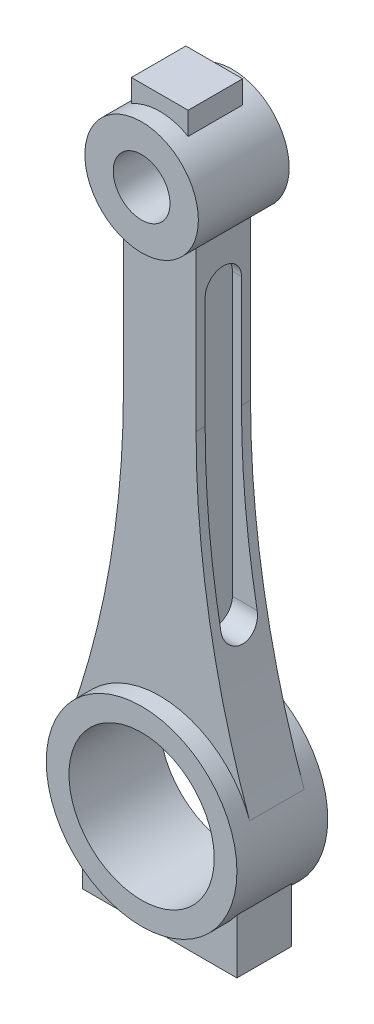
from build123d import *

# Parameters (mm, degrees)
SKETCH1_R             = 21
SKETCH1_R_2           = 16
BOSS_EXTRUDE1_DEPTH   = 10
SKETCH1_R_3           = 12.5
SKETCH1_R_4           = 6.25
BOSS_EXTRUDE1_2_DEPTH = 10
BOSS_EXTRUDE2_DEPTH   = 6
CUT_EXTRUDE1_START    = 6
CUT_EXTRUDE1_DEPTH    = 16
CUT_EXTRUDE3_START    = -6
CUT_EXTRUDE3_DEPTH    = 12


with BuildPart() as part:
    # Sketch1 → Boss-Extrude1 (new body, symmetric)
    with BuildSketch(Plane.XY):
        Circle(SKETCH1_R)
        Circle(SKETCH1_R_2, mode=Mode.SUBTRACT)
    extrude(amount=BOSS_EXTRUDE1_DEPTH, both=True)



with BuildPart() as body_2:
    # Sketch1 → Boss-Extrude1 2 (new body, symmetric)
    with BuildSketch(Plane.XY):
        with Locations((0, 120)):
            Circle(SKETCH1_R_3)
        with Locations((0, 120)):
            Circle(SKETCH1_R_4, mode=Mode.SUBTRACT)
    extrude(amount=BOSS_EXTRUDE1_2_DEPTH, both=True)


with BuildPart() as part_1:
    add(part.part)

    add(body_2.part)  # Boss-Extrude2 merges body 2
    # Sketch1_3 → Boss-Extrude2 (add, symmetric)
    with BuildSketch(Plane.XY):
        with BuildLine():
            Line((-8, 110.395313644), (-8, 75.395313644))
            ThreePointArc((-8, 75.395313644), (-10.96842855, 40.709642053), (-19.787382488, 7.032744434))
            ThreePointArc((-19.787382488, 7.032744434), (0, 21), (19.787382488, 7.032744434))
            ThreePointArc((19.787382488, 7.032744434), (10.96842855, 40.709642053), (8, 75.395313644))
            Line((8, 75.395313644), (8, 110.395313644))
            ThreePointArc((8, 110.395313644), (0, 107.5), (-8, 110.395313644))
        make_face()
        with BuildLine():
            Line((-6.25, 135.825317547), (-6.25, 130.825317547))
            ThreePointArc((-6.25, 130.825317547), (0, 132.5), (6.25, 130.825317547))
            Line((6.25, 130.825317547), (6.25, 135.825317547))
            Line((6.25, 135.825317547), (-6.25, 135.825317547))
        make_face()
        with BuildLine():
            ThreePointArc((17, -12.328828006), (0, -21), (-17, -12.328828006))
            Line((-17, -12.328828006), (-17, -24.328828006))
            Line((-17, -24.328828006), (17, -24.328828006))
            Line((17, -24.328828006), (17, -12.328828006))
        make_face()
    extrude(amount=BOSS_EXTRUDE2_DEPTH, both=True)

    # Sketch2 → Cut-Extrude1 (cut, through all)
    with BuildSketch(Plane(origin=(0, 0, 0), x_dir=(0, 0, -1), z_dir=(1, 0, 0)).offset(CUT_EXTRUDE1_START)):
        with BuildLine():
            Line((4, 100), (4, 38))
            ThreePointArc((4, 38), (0, 34), (-4, 38))
            Line((-4, 38), (-4, 100))
            ThreePointArc((-4, 100), (0, 104), (4, 100))
        make_face()
    extrude(amount=CUT_EXTRUDE1_DEPTH, mode=Mode.SUBTRACT)

    # Sketch2_3 → Cut-Extrude3 (cut)
    with BuildSketch(Plane(origin=(0, 0, 0), x_dir=(0, 0, -1), z_dir=(1, 0, 0)).offset(CUT_EXTRUDE3_START)):
        with BuildLine():
            Line((4, 100), (4, 38))
            ThreePointArc((4, 38), (0, 34), (-4, 38))
            Line((-4, 38), (-4, 100))
            ThreePointArc((-4, 100), (0, 104), (4, 100))
        make_face()
    extrude(amount=-CUT_EXTRUDE3_DEPTH, mode=Mode.SUBTRACT)


solid = part_1.part
